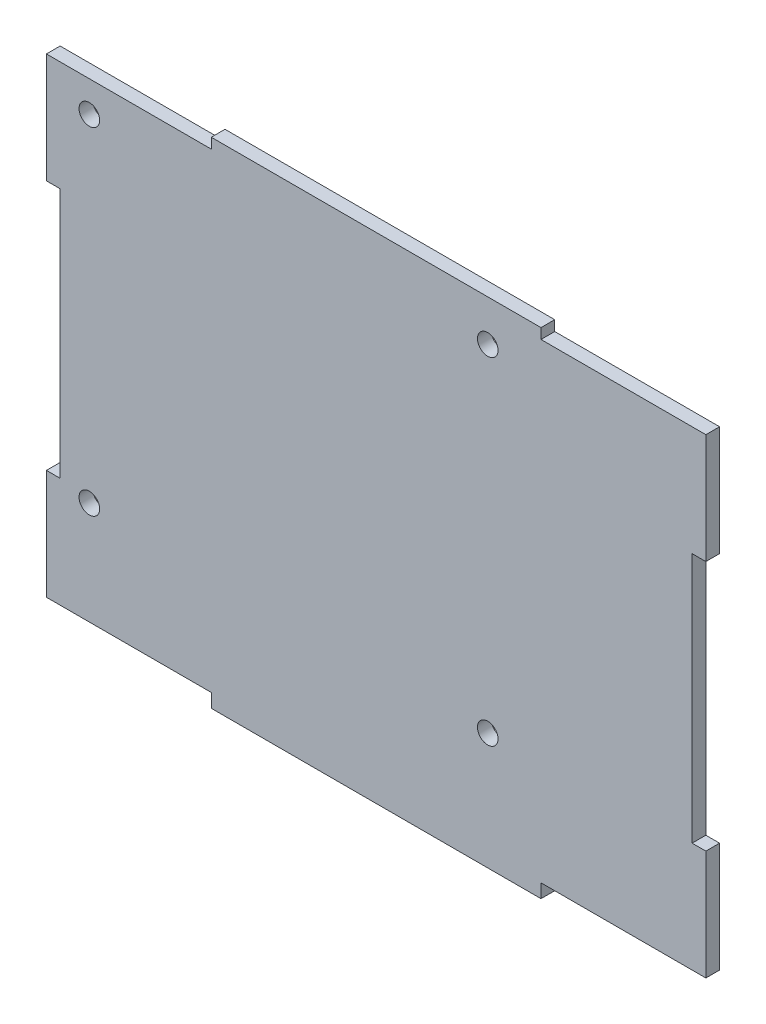
from build123d import *

# Parameters (mm, degrees)
SKETCH_1_W          = 96
SKETCH_1_H          = 72
EXTRUDE_1_DEPTH     = 2
SKETCH_2_R          = 1.5
CUT_EXTRUDE_1_DEPTH = 3
SKETCH_3_W          = 24
SKETCH_3_H          = 2
CUT_EXTRUDE_2_DEPTH = 3
SKETCH_4_W          = 24
SKETCH_4_H          = 2
CUT_EXTRUDE_3_DEPTH = 3
SKETCH_5_W          = 2
SKETCH_5_H          = 36.5
CUT_EXTRUDE_4_DEPTH = 3
SKETCH_6_W          = 2
SKETCH_6_H          = 36.5
CUT_EXTRUDE_5_DEPTH = 3


with BuildPart() as part:
    # ｽｹｯﾁ1 → ﾎﾞｽ - 押し出し1 (new body)
    with BuildSketch(Plane.XY):
        with Locations((2.027244426, 13.573770492)):
            Rectangle(SKETCH_1_W, SKETCH_1_H)
    extrude(amount=EXTRUDE_1_DEPTH)

    # ｽｹｯﾁ2 → ｶｯﾄ - 押し出し1 (cut, through all)
    with BuildSketch(Plane(origin=(0, 0, 0), x_dir=(-1, 0, 0), z_dir=(0, 0, -1))):
        with Locations((-18.277244426, -5.426229508)):
            Circle(SKETCH_2_R)
        with Locations((-18.277244426, 43.573770492)):
            Circle(SKETCH_2_R)
        with Locations((39.722755574, -5.426229508)):
            Circle(SKETCH_2_R)
        with Locations((39.722755574, 43.573770492)):
            Circle(SKETCH_2_R)
    extrude(amount=-CUT_EXTRUDE_1_DEPTH, mode=Mode.SUBTRACT)

    # ｽｹｯﾁ3 → ｶｯﾄ - 押し出し2 (cut, through all)
    with BuildSketch(Plane(origin=(0, 0, 0), x_dir=(-1, 0, 0), z_dir=(0, 0, -1))):
        with Locations((33.972755574, -21.426229508)):
            Rectangle(SKETCH_3_W, SKETCH_3_H)
        with Locations((-38.027244426, -21.426229508)):
            Rectangle(SKETCH_3_W, SKETCH_3_H)
    extrude(amount=-CUT_EXTRUDE_2_DEPTH, mode=Mode.SUBTRACT)

    # ｽｹｯﾁ4 → ｶｯﾄ - 押し出し3 (cut, through all)
    with BuildSketch(Plane(origin=(0, 0, 0), x_dir=(-1, 0, 0), z_dir=(0, 0, -1))):
        with Locations((33.972755574, 49.073770492)):
            Rectangle(SKETCH_4_W, SKETCH_4_H)
        with Locations((-38.027244426, 49.073770492)):
            Rectangle(SKETCH_4_W, SKETCH_4_H)
    extrude(amount=-CUT_EXTRUDE_3_DEPTH, mode=Mode.SUBTRACT)

    # ｽｹｯﾁ5 → ｶｯﾄ - 押し出し4 (cut, through all)
    with BuildSketch(Plane(origin=(0, 0, 0), x_dir=(-1, 0, 0), z_dir=(0, 0, -1))):
        with Locations((44.972755574, 13.823770492)):
            Rectangle(SKETCH_5_W, SKETCH_5_H)
    extrude(amount=-CUT_EXTRUDE_4_DEPTH, mode=Mode.SUBTRACT)

    # ｽｹｯﾁ6 → ｶｯﾄ - 押し出し5 (cut, through all)
    with BuildSketch(Plane(origin=(0, 0, 0), x_dir=(-1, 0, 0), z_dir=(0, 0, -1))):
        with Locations((-49.027244426, 13.823770492)):
            Rectangle(SKETCH_6_W, SKETCH_6_H)
    extrude(amount=-CUT_EXTRUDE_5_DEPTH, mode=Mode.SUBTRACT)


solid = part.part
